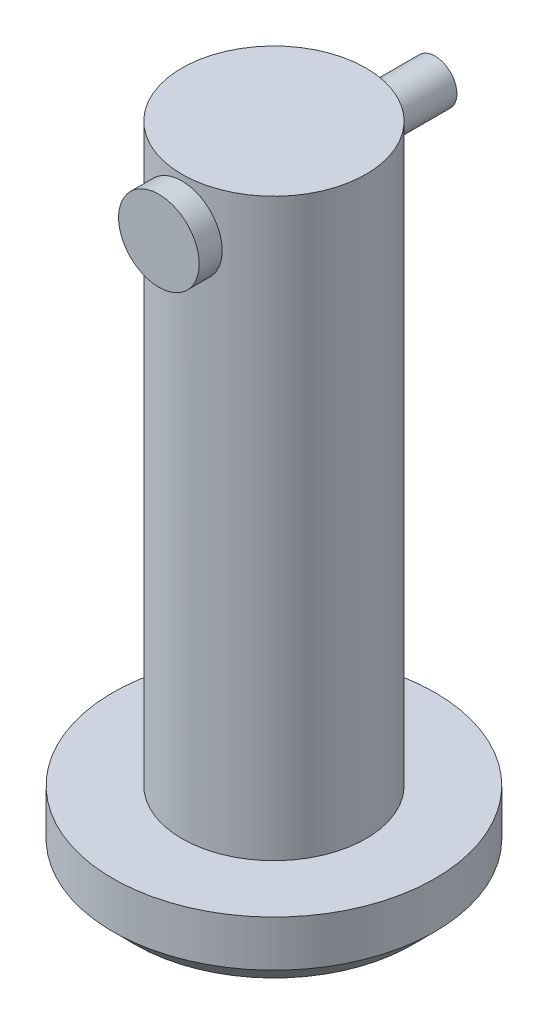
from build123d import *

# Parameters (mm, degrees)
SKETCH1_R                = 4
BOSS_EXTRUDE1_DEPTH      = 25
SKETCH2_R                = 7
BOSS_EXTRUDE2_DEPTH      = 3
CHAMFER1_SIZE            = 1
CUT_EXTRUDE1_DEPTH       = 10
CUT_EXTRUDE1_DEPTH_BACK  = 10
SKETCH3_R                = 1
BOSS_EXTRUDE3_DEPTH      = 5
BOSS_EXTRUDE3_DEPTH_BACK = 7
SKETCH4_R                = 0.95
SKETCH5_R                = 1.75
BOSS_EXTRUDE4_DEPTH      = 1


with BuildPart() as part:
    # Sketch1 → Boss-Extrude1 (new body)
    with BuildSketch(Plane(origin=(0, 0, 0), x_dir=(1, 0, 0), z_dir=(0, 1, 0))):
        Circle(SKETCH1_R)
    extrude(amount=BOSS_EXTRUDE1_DEPTH)

    # Sketch2 → Boss-Extrude2 (add)
    with BuildSketch(Plane.XZ):
        Circle(SKETCH2_R)
    extrude(amount=BOSS_EXTRUDE2_DEPTH)

    # Chamfer1
    chamfer1_edges = [part.edges().sort_by_distance(p)[0] for p in [
        (-7, -3, 0),
    ]]
    chamfer(chamfer1_edges, length=CHAMFER1_SIZE)

    # Sketch3 → Cut-Extrude1 (cut, two sides: drawn at the far end of the back side and taken through both)
    with BuildSketch(Plane.XY.offset(-CUT_EXTRUDE1_DEPTH_BACK)):
        with Locations((0, 23)):
            Circle(SKETCH3_R)
    extrude(amount=CUT_EXTRUDE1_DEPTH + CUT_EXTRUDE1_DEPTH_BACK, mode=Mode.SUBTRACT)


with BuildPart() as body_2:
    # Sketch4 → Boss-Extrude3 (new, two sides: drawn at the far end of the back side and taken through both)
    with BuildSketch(Plane.XY.offset(-BOSS_EXTRUDE3_DEPTH_BACK)):
        with Locations((0, 23)):
            Circle(SKETCH4_R)
    extrude(amount=BOSS_EXTRUDE3_DEPTH + BOSS_EXTRUDE3_DEPTH_BACK)

    # Sketch5 → Boss-Extrude4 (add)
    with BuildSketch(Plane.XY.offset(5)):
        with Locations((0, 23)):
            Circle(SKETCH5_R)
    extrude(amount=-BOSS_EXTRUDE4_DEPTH)


solid = Compound([part.part, body_2.part])
